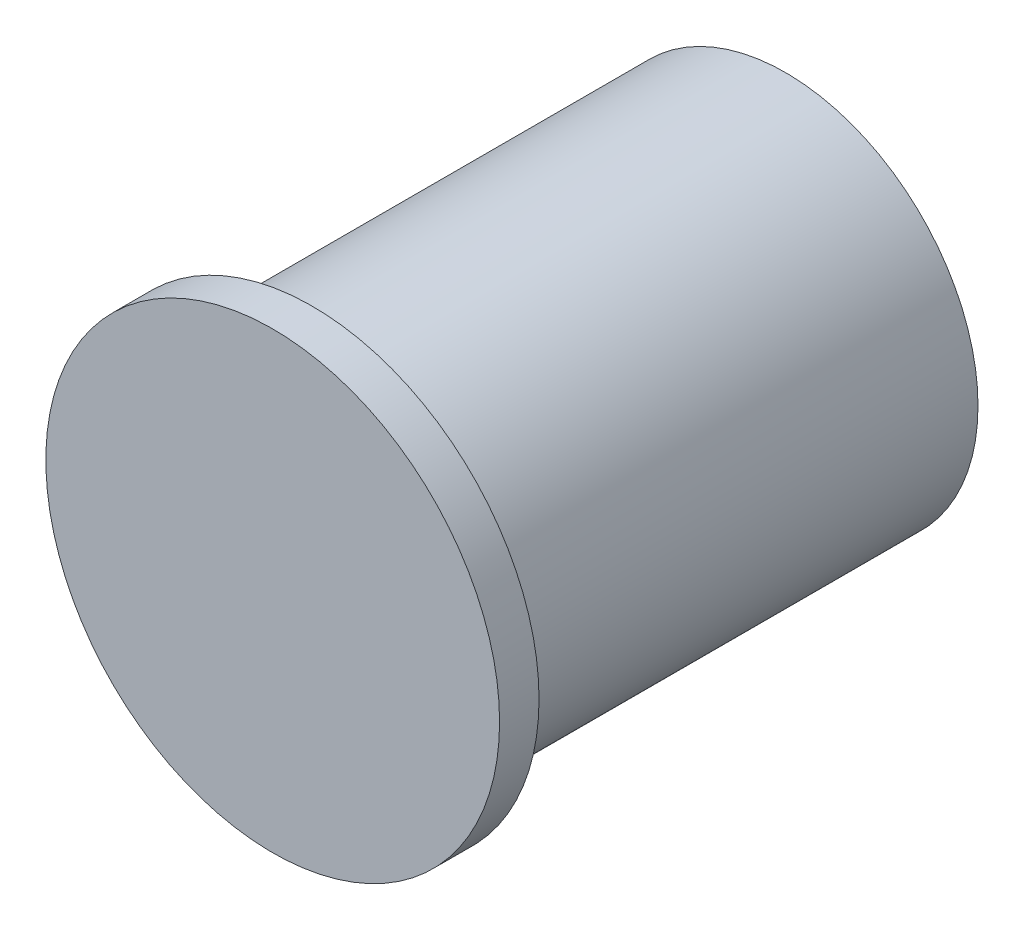
from build123d import *

# Parameters (mm, degrees)
SKETCH1_R           = 9.75
BOSS_EXTRUDE1_DEPTH = 24
SKETCH3_R           = 11.5
BOSS_EXTRUDE2_DEPTH = 2
SKETCH4_R           = 9
SKETCH4_R_2         = 8
CUT_EXTRUDE1_DEPTH  = 2


with BuildPart() as part:
    # Sketch1 → Boss-Extrude1 (new body)
    with BuildSketch(Plane.XY):
        Circle(SKETCH1_R)
    extrude(amount=BOSS_EXTRUDE1_DEPTH)

    # Sketch3 → Boss-Extrude2 (add)
    with BuildSketch(Plane.XY.offset(24)):
        Circle(SKETCH3_R)
    extrude(amount=BOSS_EXTRUDE2_DEPTH)

    # Sketch4 → Cut-Extrude1 (cut)
    with BuildSketch(Plane(origin=(0, 0, 0), x_dir=(-1, 0, 0), z_dir=(0, 0, -1))):
        Circle(SKETCH4_R)
        Circle(SKETCH4_R_2, mode=Mode.SUBTRACT)
    extrude(amount=-CUT_EXTRUDE1_DEPTH, mode=Mode.SUBTRACT)


solid = part.part
